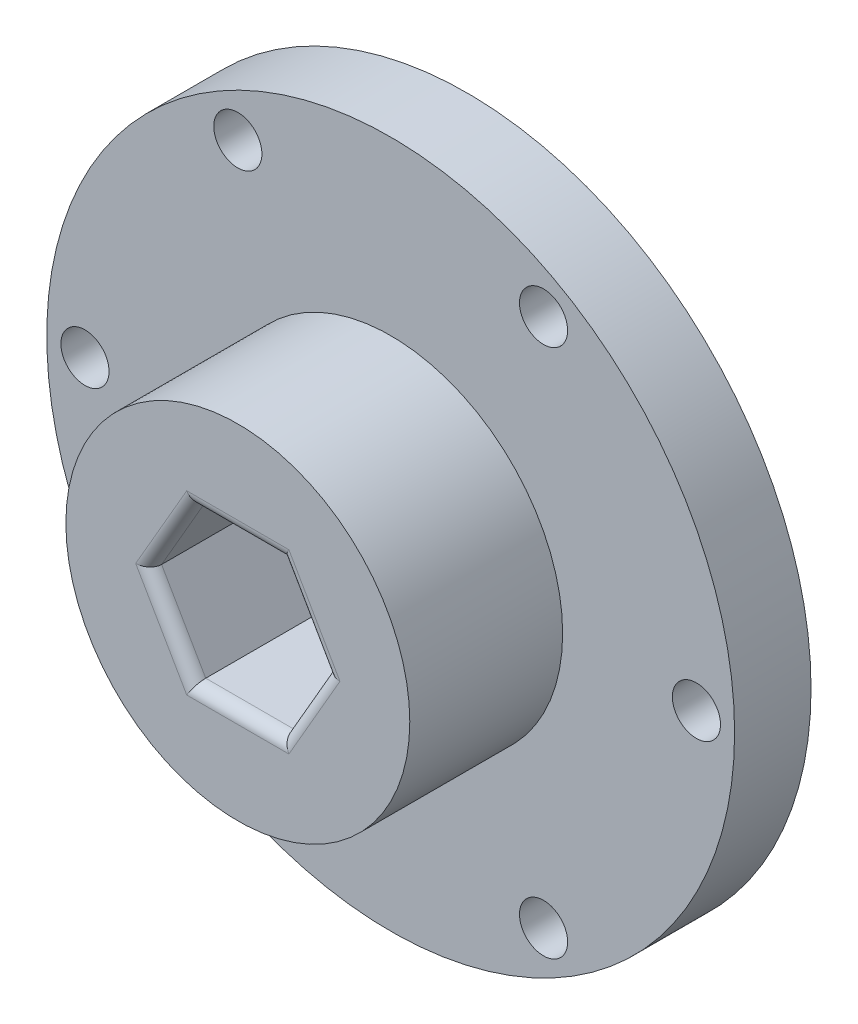
from build123d import *

# Parameters (mm, degrees)
SKETCH1_R           = 28.575
BOSS_EXTRUDE1_DEPTH = 6.35
SKETCH2_R           = 14.2875
BOSS_EXTRUDE2_DEPTH = 12.7
CUT_EXTRUDE1_DEPTH  = 20.05
SKETCH4_R           = 2
CUT_EXTRUDE2_DEPTH  = 7.35
FILLET1_R           = 1


with BuildPart() as part:
    # Sketch1 → Boss-Extrude1 (new body)
    with BuildSketch(Plane.XY):
        Circle(SKETCH1_R)
    extrude(amount=BOSS_EXTRUDE1_DEPTH)

    # Sketch2 → Boss-Extrude2 (add)
    with BuildSketch(Plane.XY.offset(6.35)):
        Circle(SKETCH2_R)
    extrude(amount=BOSS_EXTRUDE2_DEPTH)

    # Sketch3 → Cut-Extrude1 (cut, through all)
    with BuildSketch(Plane.XY.offset(19.05)):
        Polygon((7.332348419, 0), (3.666174209, 6.35), (-3.666174209, 6.35), (-7.332348419, 0), (-3.666174209, -6.35), (3.666174209, -6.35), align=None)
    extrude(amount=-CUT_EXTRUDE1_DEPTH, mode=Mode.SUBTRACT)

    # Sketch4 → Cut-Extrude2 (cut, through all)
    with BuildSketch(Plane.XY.offset(6.35)):
        with Locations((25.4, 0)):
            Circle(SKETCH4_R)
        with Locations((12.7, -21.997045256)):
            Circle(SKETCH4_R)
        with Locations((-12.7, -21.997045256)):
            Circle(SKETCH4_R)
        with Locations((-25.4, 0)):
            Circle(SKETCH4_R)
        with Locations((-12.7, 21.997045256)):
            Circle(SKETCH4_R)
        with Locations((12.7, 21.997045256)):
            Circle(SKETCH4_R)
    extrude(amount=-CUT_EXTRUDE2_DEPTH, mode=Mode.SUBTRACT)

    # Fillet1
    fillet1_edges = [part.edges().sort_by_distance(p)[0] for p in [
        (5.499261314, -3.175, 19.05),
        (5.499261314, 3.175, 19.05),
        (0, 6.35, 19.05),
        (-5.499261314, 3.175, 19.05),
        (-5.499261314, -3.175, 19.05),
        (0, -6.35, 19.05),
    ]]
    fillet(fillet1_edges, radius=FILLET1_R)


solid = part.part
